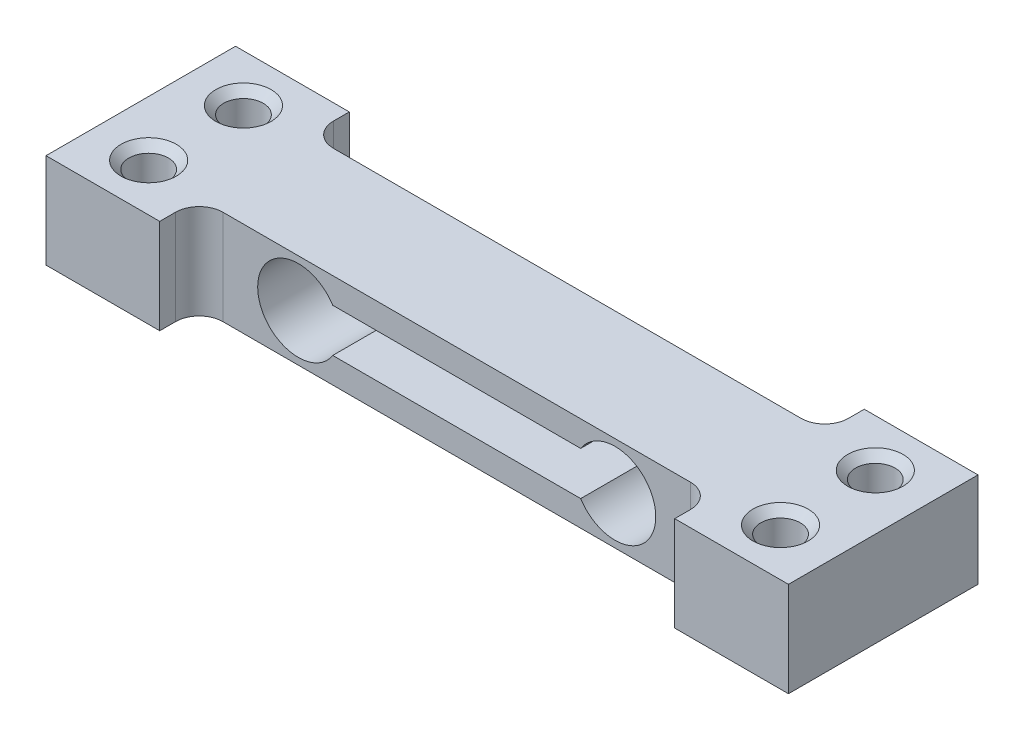
from build123d import *

# Parameters (mm, degrees)
BOSS_EXTRUDE1_DEPTH        = 3
CUT_EXTRUDE1_DEPTH         = 10.5
M3_TAPPED_HOLE1_AT_2_COUNT = 2
M3_TAPPED_HOLE1_AT_2_PITCH = 6


with BuildPart() as part:
    # Sketch1 → Boss-Extrude1 (new body, symmetric)
    with BuildSketch(Plane(origin=(0, 0, 0), x_dir=(1, 0, 0), z_dir=(0, 1, 0))):
        with BuildLine():
            Line((0, -3.5), (0, 3.5))
            Line((0, 3.5), (14.8, 3.5))
            ThreePointArc((14.8, 3.5), (15.860660172, 3.939339828), (16.3, 5))
            Line((16.3, 5), (16.3, 6))
            Line((16.3, 6), (23.5, 6))
            Line((23.5, 6), (23.5, -6))
            Line((23.5, -6), (16.3, -6))
            Line((16.3, -6), (16.3, -5))
            ThreePointArc((16.3, -5), (15.860660172, -3.939339828), (14.8, -3.5))
            Line((14.8, -3.5), (0, -3.5))
        make_face()
    extrude(amount=BOSS_EXTRUDE1_DEPTH, both=True)

    # Sketch2 → Cut-Extrude1 (cut, through all)
    with BuildSketch(Plane.XY.offset(3.5)):
        with BuildLine():
            ThreePointArc((7.847845894, 1.375), (7.45, 0), (7.847845894, -1.375))
            Line((7.847845894, -1.375), (10.025, -1.375))
            Line((10.025, -1.375), (10.025, 1.375))
            Line((10.025, 1.375), (7.847845894, 1.375))
        make_face()
        with BuildLine():
            Line((10.025, -1.375), (7.847845894, -1.375))
            ThreePointArc((7.847845894, -1.375), (10.740700069, -2.473539652), (12.6, 0))
            ThreePointArc((12.6, 0), (10.740700069, 2.473539652), (7.847845894, 1.375))
            Line((7.847845894, 1.375), (10.025, 1.375))
            Line((10.025, 1.375), (10.025, -1.375))
        make_face()
        with BuildLine():
            Line((0, 1.375), (0, -1.375))
            Line((0, -1.375), (7.847845894, -1.375))
            ThreePointArc((7.847845894, -1.375), (7.45, 0), (7.847845894, 1.375))
            Line((7.847845894, 1.375), (0, 1.375))
        make_face()
    extrude(amount=-CUT_EXTRUDE1_DEPTH, mode=Mode.SUBTRACT)

    # Sketch5 → M3 Tapped Hole1 (revolve, cut)
    with BuildSketch(Plane(origin=(20, 3, -3), x_dir=(0, 0, 1), z_dir=(1, 0, 0))):
        Polygon((0, 0), (0, 6), (1.75, 6), (1.25, 5.5), (1.25, 0.5), (1.75, 0), align=None)
    m3_tapped_hole1 = revolve(axis=Axis((20, 9.35, -3), (0, -1, 0)), mode=Mode.SUBTRACT)

    # M3 Tapped Hole1 at 2: M3 Tapped Hole1 ×2
    with Locations(*[(0, 0, i * M3_TAPPED_HOLE1_AT_2_PITCH) for i in range(1, M3_TAPPED_HOLE1_AT_2_COUNT)]):
        add(m3_tapped_hole1, mode=Mode.SUBTRACT)

    # Mirror1: part across plane


with BuildPart() as part_1:
    add(part.part)
    add(part.part.mirror(Plane(origin=(0, 0, 0), x_dir=(0, 0, 1), z_dir=(1, 0, 0))))


solid = part_1.part
